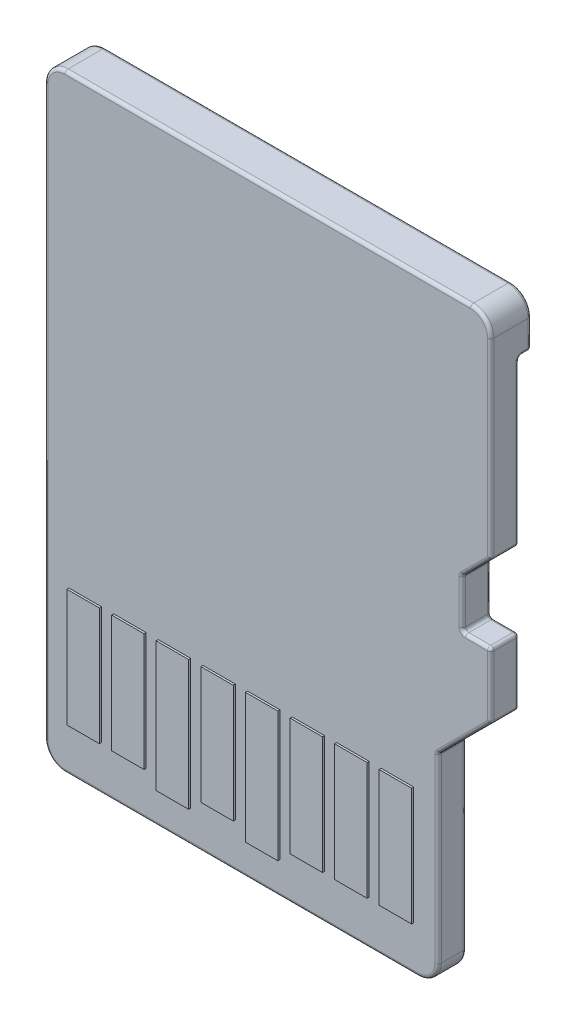
from build123d import *

# Parameters (mm, degrees)
BOSS_EXTRUDE1_DEPTH      = 0.1
BOSS_EXTRUDE1_DEPTH_BACK = 0.6
BOSS_EXTRUDE2_DEPTH      = 0.3
SKETCH3_W                = 0.8
SKETCH3_H                = 2.9
SKETCH3_H_2              = 3.2
BOSS_EXTRUDE3_DEPTH      = 0.05
CUT_EXTRUDE1_DEPTH       = 0.7
FILLET1_R                = 0.5
FILLET2_R                = 0.08


with BuildPart() as part:
    # Sketch1 → Boss-Extrude1 (new body, two sides)
    with BuildSketch(Plane.XY) as boss_extrude1_sk:
        Polygon((-5.5, 30.230563632), (5.5, 30.230563632), (5.5, 21.530563632), (4.2, 20.230563632), (4.2, 15.230563632), (-5.5, 15.230563632), align=None)
    extrude(amount=BOSS_EXTRUDE1_DEPTH)
    extrude(boss_extrude1_sk.sketch, amount=-BOSS_EXTRUDE1_DEPTH_BACK)

    # Sketch2 → Boss-Extrude2 (add)
    with BuildSketch(Plane(origin=(0, 0, -0.6), x_dir=(-1, 0, 0), z_dir=(0, 0, -1))):
        with BuildLine():
            Line((-5.5, 30.230563632), (5.5, 30.230563632))
            Line((5.5, 30.230563632), (5.5, 29.030563632))
            ThreePointArc((5.5, 29.030563632), (0, 28.430563632), (-5.5, 29.030563632))
            Line((-5.5, 29.030563632), (-5.5, 30.230563632))
        make_face()
    extrude(amount=BOSS_EXTRUDE2_DEPTH)

    # Sketch3 → Boss-Extrude3 (add)
    with BuildSketch(Plane.XY.offset(0.1)):
        with Locations((-4.5, 17.780563632)):
            Rectangle(SKETCH3_W, SKETCH3_H)
        with Locations((3.2, 17.780563632)):
            Rectangle(SKETCH3_W, SKETCH3_H)
        with Locations((-3.4, 17.780563632)):
            Rectangle(SKETCH3_W, SKETCH3_H)
        with Locations((-1.2, 17.780563632)):
            Rectangle(SKETCH3_W, SKETCH3_H)
        with Locations((1, 17.780563632)):
            Rectangle(SKETCH3_W, SKETCH3_H)
        with Locations((2.1, 17.780563632)):
            Rectangle(SKETCH3_W, SKETCH3_H)
        with Locations((-2.3, 17.630563632)):
            Rectangle(SKETCH3_W, SKETCH3_H_2)
        with Locations((-0.1, 17.630563632)):
            Rectangle(SKETCH3_W, SKETCH3_H_2)
    extrude(amount=BOSS_EXTRUDE3_DEPTH)

    # Sketch4 → Cut-Extrude1 (cut)
    with BuildSketch(Plane(origin=(0, 0, -0.6), x_dir=(-1, 0, 0), z_dir=(0, 0, -1))):
        Polygon((-5.5, 23.130563632), (-5.5, 25.030563632), (-4.8, 24.330563632), (-4.8, 23.130563632), align=None)
    extrude(amount=-CUT_EXTRUDE1_DEPTH, mode=Mode.SUBTRACT)

    # Fillet1
    fillet1_edges = [part.edges().sort_by_distance(p)[0] for p in [
        (-5.5, 15.230563632, -0.25),
        (-5.5, 30.230563632, -0.4),
        (5.5, 30.230563632, -0.4),
        (4.2, 15.230563632, -0.25),
    ]]
    fillet(fillet1_edges, radius=FILLET1_R)

    # Fillet2
    fillet2_edges = [part.edges().sort_by_distance(p)[0] for p in [
        (4.85, 20.880563632, 0.1),
        (5.5, 21.530563632, -0.25),
        (4.2, 20.230563632, -0.25),
        (5.5, 22.330563632, 0.1),
        (5.5, 22.330563632, -0.6),
        (4.85, 20.880563632, -0.6),
        (5.5, 27.030563632, -0.6),
        (5.5, 27.380563632, 0.1),
        (5.5, 25.030563632, -0.25),
        (4.8, 24.330563632, -0.25),
        (4.8, 23.130563632, -0.25),
        (5.5, 23.130563632, -0.25),
        (5.15, 24.680563632, -0.6),
        (5.15, 23.130563632, -0.6),
        (4.8, 23.730563632, -0.6),
        (5.15, 24.680563632, 0.1),
        (4.8, 23.730563632, 0.1),
        (5.15, 23.130563632, 0.1),
        (0, 30.230563632, -0.9),
        (0, 30.230563632, 0.1),
        (5.5, 29.380563632, -0.9),
        (-5.353553391, 30.084117023, -0.9),
        (5.353553391, 30.084117023, -0.9),
        (-5.5, 22.730563632, 0.1),
        (-0.65, 15.230563632, 0.1),
        (4.2, 17.980563632, 0.1),
        (4.053553391, 15.377010242, 0.1),
        (-5.353553391, 15.377010242, 0.1),
        (-5.353553391, 30.084117023, 0.1),
        (5.353553391, 30.084117023, 0.1),
        (-0.65, 15.230563632, -0.6),
        (4.2, 17.980563632, -0.6),
        (4.053553391, 15.377010242, -0.6),
        (-5.353553391, 15.377010242, -0.6),
        (-5.5, 22.380563632, -0.6),
        (0, 28.430563632, -0.6),
        (5.5, 29.030563632, -0.75),
        (-5.5, 29.030563632, -0.75),
        (0, 28.430563632, -0.9),
        (-5.5, 29.380563632, -0.9),
    ]]
    fillet(fillet2_edges, radius=FILLET2_R)


solid = part.part
